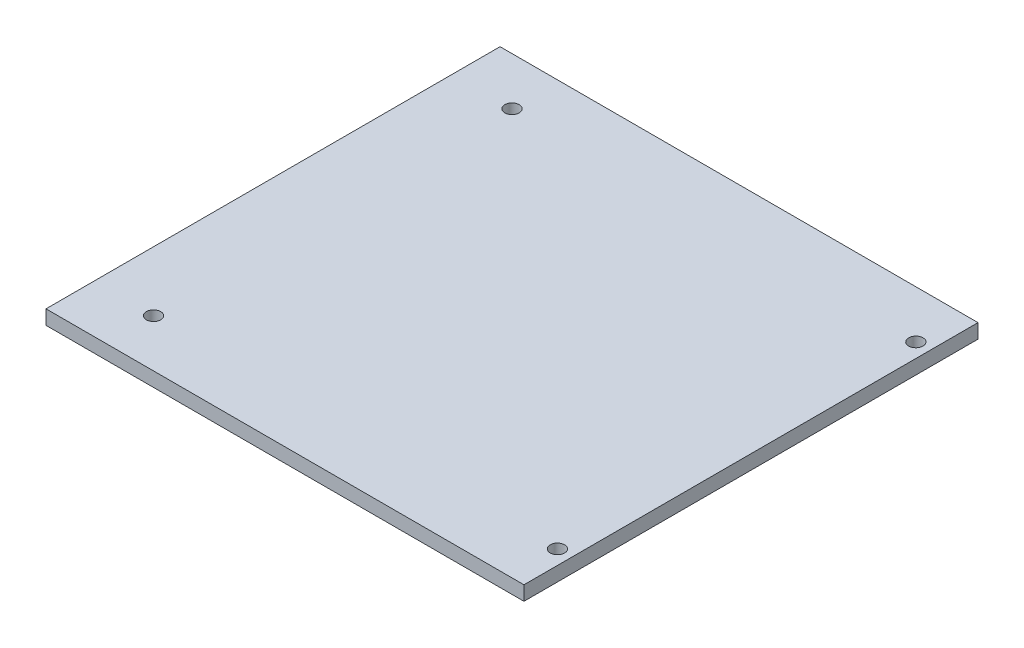
from build123d import *

# Parameters (mm, degrees)
SKETCH1_W           = 100
SKETCH1_H           = 95
SKETCH1_R           = 1.5
BOSS_EXTRUDE1_DEPTH = 3


with BuildPart() as part:
    # Sketch1 → Boss-Extrude1 (new body)
    with BuildSketch(Plane(origin=(0, 0, 0), x_dir=(1, 0, 0), z_dir=(0, 1, 0))):
        Rectangle(SKETCH1_W, SKETCH1_H)
        with Locations((-37.5, 37.5)):
            Circle(SKETCH1_R, mode=Mode.SUBTRACT)
        with Locations((47, 37.5)):
            Circle(SKETCH1_R, mode=Mode.SUBTRACT)
        with Locations((47, -37.5)):
            Circle(SKETCH1_R, mode=Mode.SUBTRACT)
        with Locations((-37.5, -37.5)):
            Circle(SKETCH1_R, mode=Mode.SUBTRACT)
    extrude(amount=BOSS_EXTRUDE1_DEPTH)


solid = part.part
